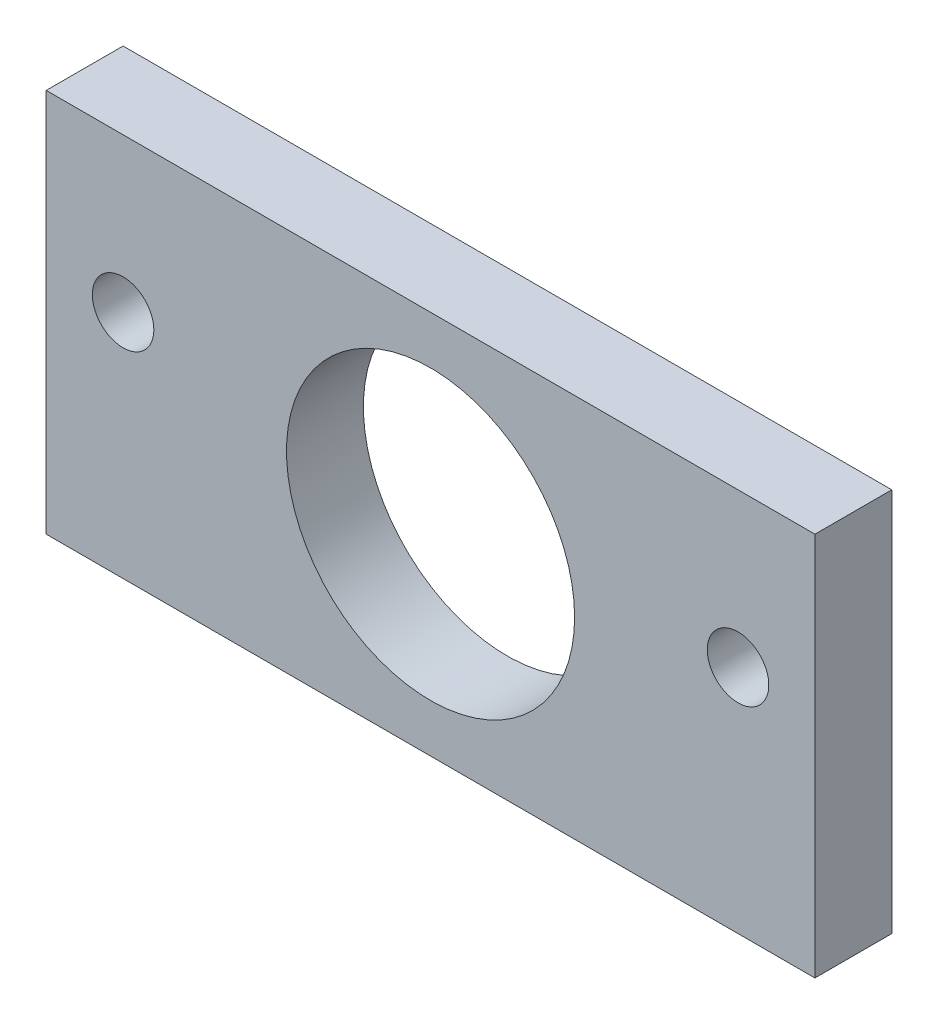
from build123d import *

# Parameters (mm, degrees)
SKETCH1_W           = 63.5
SKETCH1_H           = 31.75
SKETCH1_R           = 11.8999
SKETCH1_R_2         = 2.54
BOSS_EXTRUDE1_DEPTH = 6.35


with BuildPart() as part:
    # Sketch1 → Boss-Extrude1 (new body)
    with BuildSketch(Plane.XY):
        with Locations((31.75, 15.875)):
            Rectangle(SKETCH1_W, SKETCH1_H)
        with Locations((31.75, 15.875)):
            Circle(SKETCH1_R, mode=Mode.SUBTRACT)
        with Locations((6.35, 19.05)):
            Circle(SKETCH1_R_2, mode=Mode.SUBTRACT)
        with Locations((57.15, 19.05)):
            Circle(SKETCH1_R_2, mode=Mode.SUBTRACT)
    extrude(amount=BOSS_EXTRUDE1_DEPTH)


solid = part.part
